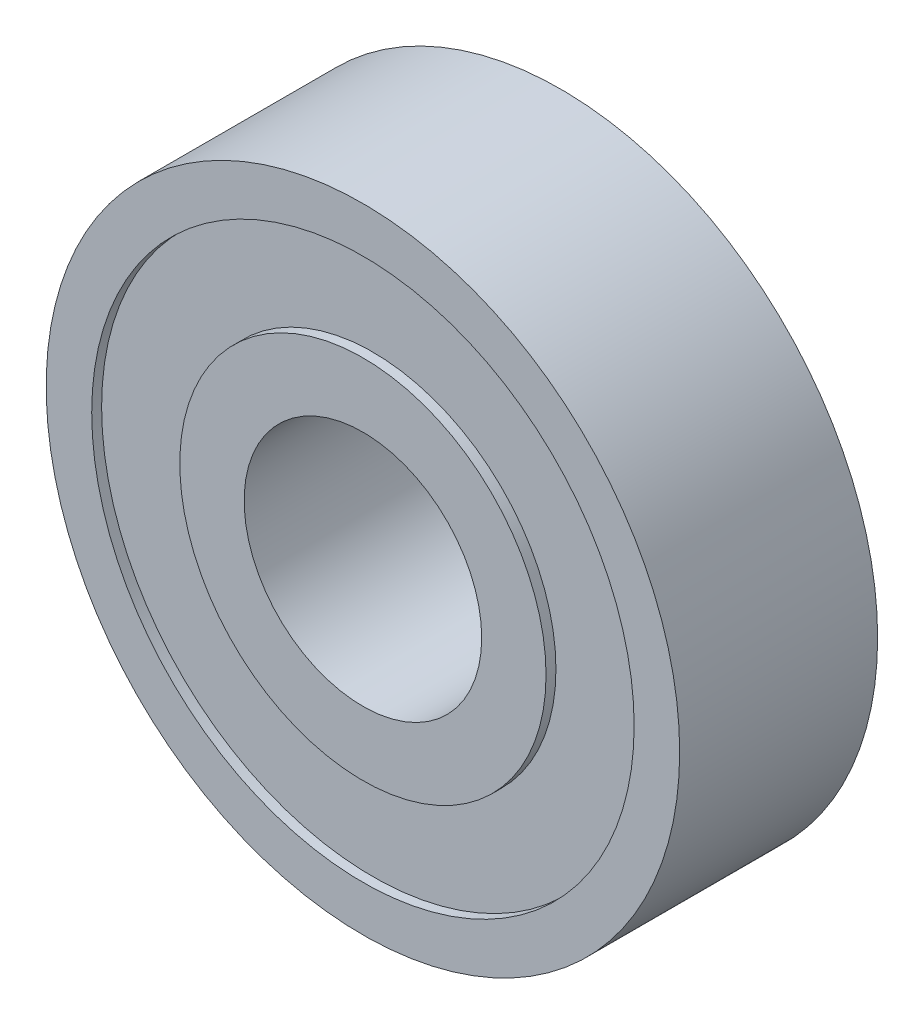
from build123d import *

# Parameters (mm, degrees)
SKETCH_1_R          = 16
EXTRUDE_1_DEPTH     = 5
SKETCH_2_R          = 6
CUT_EXTRUDE_1_DEPTH = 11
SKETCH_3_R          = 13.7
SKETCH_3_R_2        = 9.25
CUT_EXTRUDE_2_DEPTH = 0.5


with BuildPart() as part:
    # 草圖1 → 填料-伸長1 (new body, symmetric)
    with BuildSketch(Plane.XY):
        Circle(SKETCH_1_R)
    extrude(amount=EXTRUDE_1_DEPTH, both=True)

    # 草圖2 → 除料-伸長1 (cut, through all)
    with BuildSketch(Plane.XY.offset(5)):
        Circle(SKETCH_2_R)
    extrude(amount=-CUT_EXTRUDE_1_DEPTH, mode=Mode.SUBTRACT)

    # 草圖3 → 除料-伸長2 (cut)
    with BuildSketch(Plane.XY.offset(5)):
        Circle(SKETCH_3_R)
        Circle(SKETCH_3_R_2, mode=Mode.SUBTRACT)
    cut_extrude_2 = extrude(amount=-CUT_EXTRUDE_2_DEPTH, mode=Mode.SUBTRACT)

    # 鏡射1: 除料-伸長2 across plane
    add(cut_extrude_2.mirror(Plane.XY), mode=Mode.SUBTRACT)


solid = part.part
